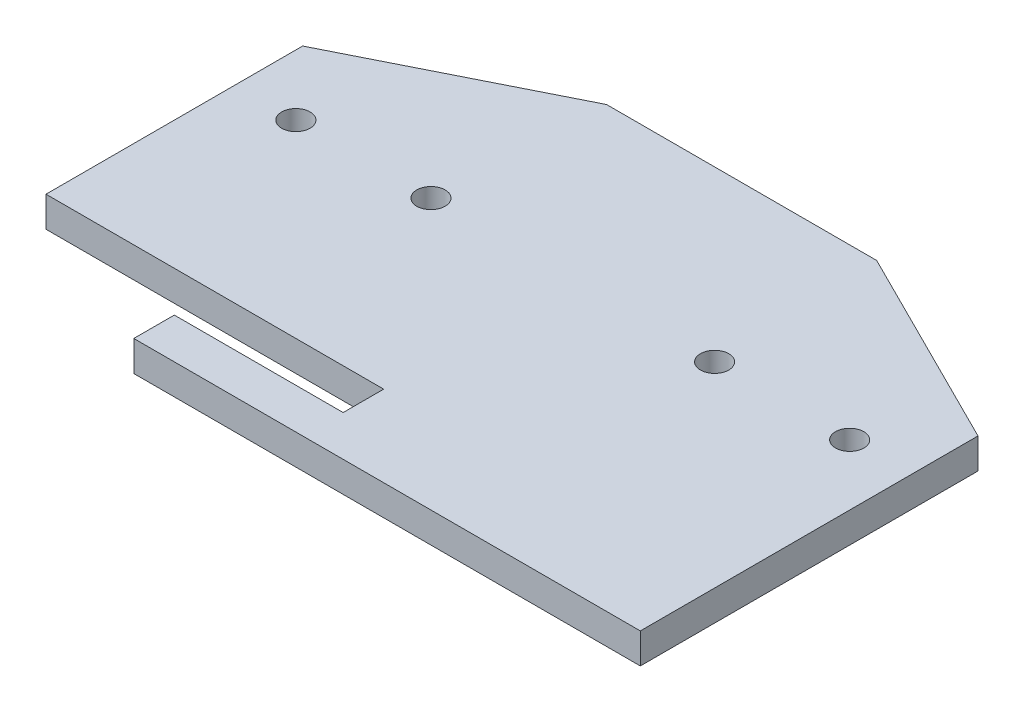
from build123d import *

# Parameters (mm, degrees)
SKETCH1_R           = 2.1
BOSS_EXTRUDE1_DEPTH = 4.5
CUT_EXTRUDE1_DEPTH  = 10


with BuildPart() as part:
    # Sketch1 → Boss-Extrude1 (new body)
    with BuildSketch(Plane(origin=(0, 0, 0), x_dir=(1, 0, 0), z_dir=(0, 1, 0))):
        Polygon((20, 40), (50, 25), (50, -25), (-50, -25), (-50, 25), (-20, 40), (0, 40), align=None)
        with Locations((-41, 15)):
            Circle(SKETCH1_R, mode=Mode.SUBTRACT)
        with Locations((41, 15)):
            Circle(SKETCH1_R, mode=Mode.SUBTRACT)
        with Locations((-21, 15)):
            Circle(SKETCH1_R, mode=Mode.SUBTRACT)
        with Locations((21, 15)):
            Circle(SKETCH1_R, mode=Mode.SUBTRACT)
    extrude(amount=BOSS_EXTRUDE1_DEPTH)

    # Sketch2 → Cut-Extrude1 (cut)
    with BuildSketch(Plane(origin=(0, 4.5, 0), x_dir=(1, 0, 0), z_dir=(0, 1, 0))):
        Polygon((-50, -19), (-50, -25), (-25, -25), (-25, -19), (0, -19), (0, -13), (-50, -13), align=None)
    extrude(amount=-CUT_EXTRUDE1_DEPTH, mode=Mode.SUBTRACT)


solid = part.part
